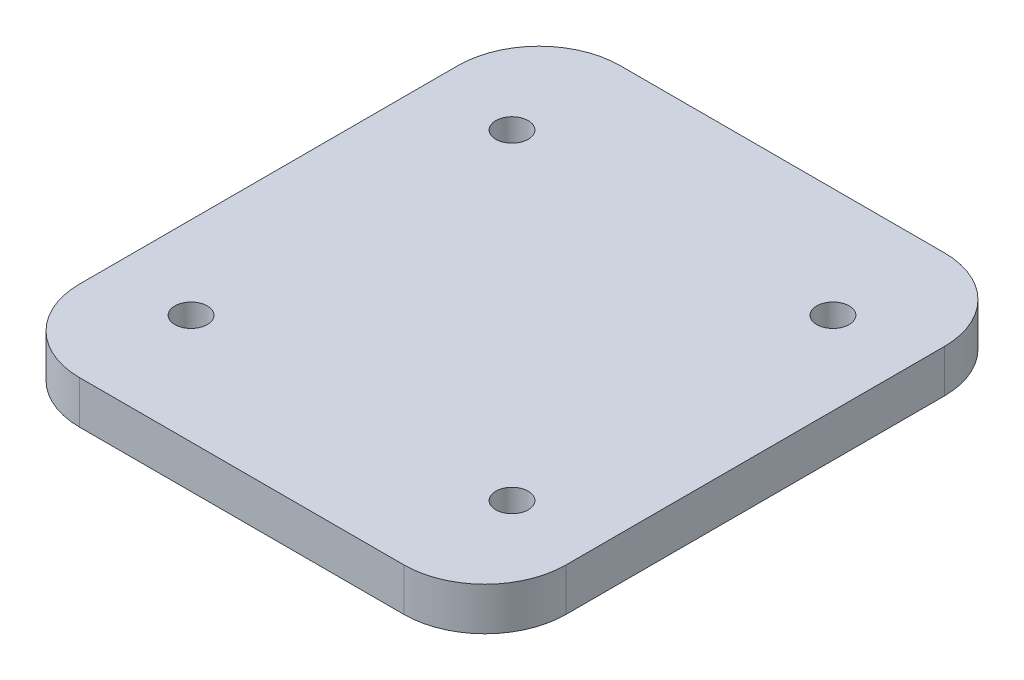
from build123d import *

# Parameters (mm, degrees)
BOSS_EXTRUDE1_DEPTH = 6.35
SKETCH2_R           = 2.4
CUT_EXTRUDE1_DEPTH  = 7.35


with BuildPart() as part:
    # Sketch1 → Boss-Extrude1 (new body)
    with BuildSketch(Plane(origin=(0, 0, 0), x_dir=(1, 0, 0), z_dir=(0, 1, 0))):
        with BuildLine():
            Line((-24, -40), (24, -40))
            ThreePointArc((24, -40), (32.485281374, -36.485281374), (36, -28))
            Line((36, -28), (36, 28))
            ThreePointArc((36, 28), (32.485281374, 36.485281374), (24, 40))
            Line((24, 40), (-24, 40))
            ThreePointArc((-24, 40), (-32.485281374, 36.485281374), (-36, 28))
            Line((-36, 28), (-36, -28))
            ThreePointArc((-36, -28), (-32.485281374, -36.485281374), (-24, -40))
        make_face()
    extrude(amount=BOSS_EXTRUDE1_DEPTH)

    # Sketch2 → Cut-Extrude1 (cut, through all)
    with BuildSketch(Plane(origin=(0, 6.35, 0), x_dir=(1, 0, 0), z_dir=(0, 1, 0))):
        with Locations((-23.75, 23.75)):
            Circle(SKETCH2_R)
        with Locations((23.75, 23.75)):
            Circle(SKETCH2_R)
        with Locations((23.75, -23.75)):
            Circle(SKETCH2_R)
        with Locations((-23.75, -23.75)):
            Circle(SKETCH2_R)
    extrude(amount=-CUT_EXTRUDE1_DEPTH, mode=Mode.SUBTRACT)


solid = part.part
